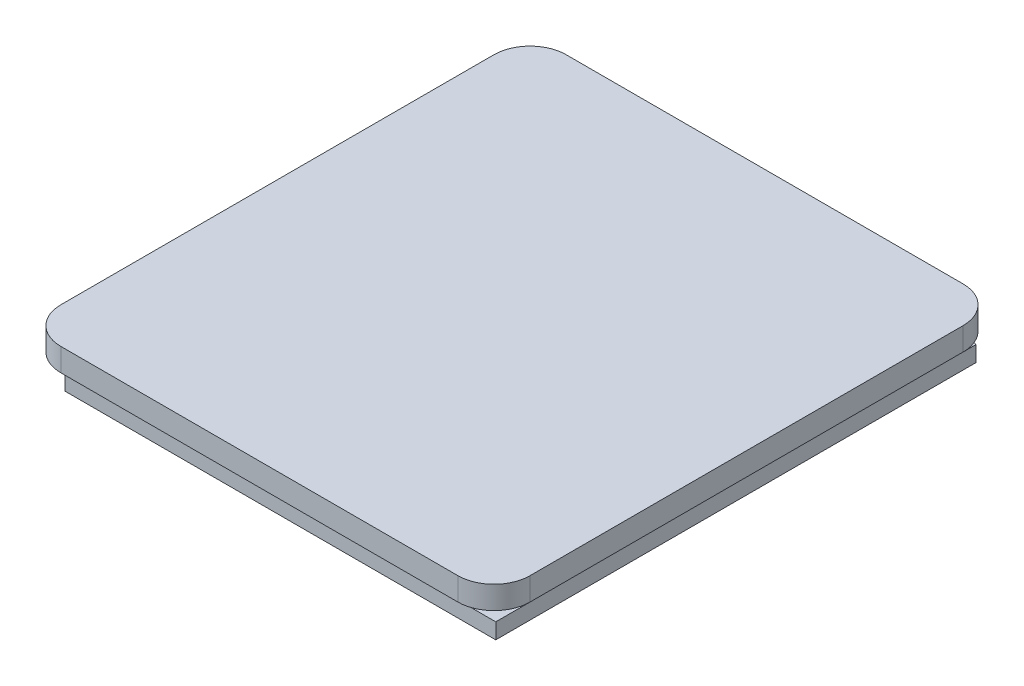
from build123d import *

# Parameters (mm, degrees)
BOSS_EXTRUDE1_DEPTH = 4.8
SKETCH3_W           = 0.3
SKETCH3_H           = 1.6
CUT_EXTRUDE1_DEPTH  = 114.8
CUT_EXTRUDE2_DEPTH  = 114.8


with BuildPart() as part:
    # Sketch2 → Boss-Extrude1 (new body)
    with BuildSketch(Plane(origin=(0, 0, 0), x_dir=(1, 0, 0), z_dir=(0, 1, 0))):
        with BuildLine():
            Line((-16.5, -21), (16.5, -21))
            ThreePointArc((16.5, -21), (18.621320344, -20.121320344), (19.5, -18))
            Line((19.5, -18), (19.5, 18))
            ThreePointArc((19.5, 18), (18.621320344, 20.121320344), (16.5, 21))
            Line((16.5, 21), (-16.5, 21))
            ThreePointArc((-16.5, 21), (-18.621320344, 20.121320344), (-19.5, 18))
            Line((-19.5, 18), (-19.5, -18))
            ThreePointArc((-19.5, -18), (-18.621320344, -20.121320344), (-16.5, -21))
        make_face()
    extrude(amount=BOSS_EXTRUDE1_DEPTH)

    # Sketch3 → Cut-Extrude1 (cut)
    with BuildSketch(Plane.XY.offset(21)):
        Polygon((-16.5, 1.3), (-16.5, 2.9), (-17.9, 2.9), (-19.5, 2.9), (-19.5, 1.3), (-19.5, 0), (-17.9, 0), (-17.9, 1.3), align=None)
        Polygon((17.9, 2.9), (16.5, 2.9), (16.5, 1.3), (17.9, 1.3), (17.9, 0), (19.5, 0), (19.5, 1.3), (19.5, 2.9), align=None)
        with Locations((-16.35, 2.1)):
            Rectangle(SKETCH3_W, SKETCH3_H)
        with Locations((16.35, 2.1)):
            Rectangle(SKETCH3_W, SKETCH3_H)
    extrude(amount=-CUT_EXTRUDE1_DEPTH, mode=Mode.SUBTRACT)

    # Sketch4 → Cut-Extrude2 (cut)
    with BuildSketch(Plane.ZY.offset(19.5)):
        Polygon((17.5, 2.9), (21, 2.9), (21, 1.2), (21, 0), (19.25, 0), (19.25, 1.3), (17.5, 1.3), align=None)
    extrude(amount=-CUT_EXTRUDE2_DEPTH, mode=Mode.SUBTRACT)


solid = part.part
